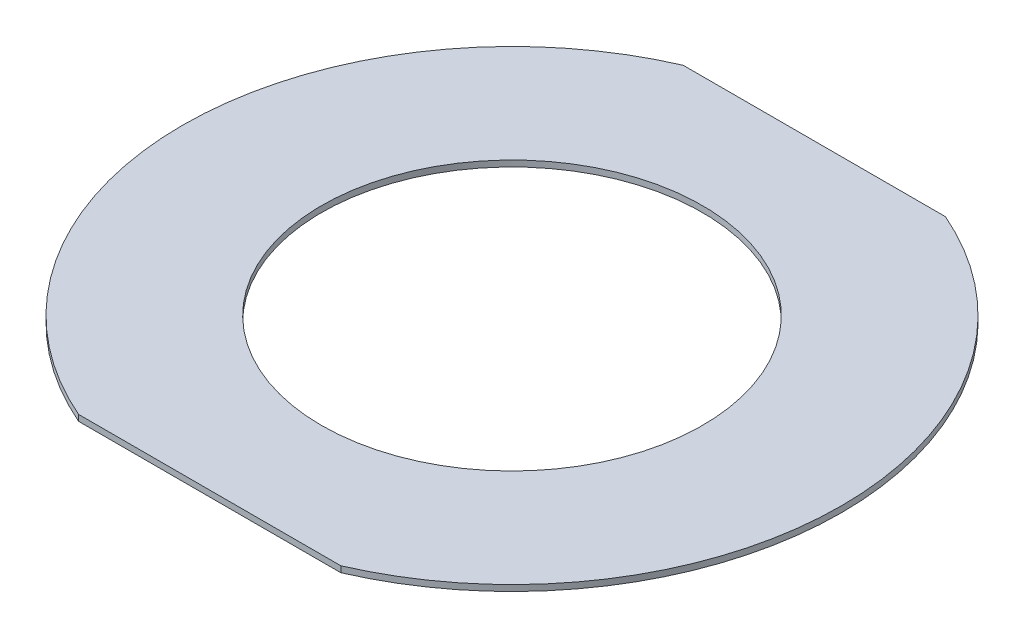
from build123d import *

# Parameters (mm, degrees)
SKETCH7_R           = 0.8001
BOSS_EXTRUDE3_DEPTH = 0.0254


with BuildPart() as part:
    # Sketch7 → Boss-Extrude3 (new body)
    with BuildSketch(Plane(origin=(0, 0, 0), x_dir=(1, 0, 0), z_dir=(0, 1, 0))):
        with BuildLine():
            Line((-0.55080531, 1.27), (0.55080531, 1.27))
            ThreePointArc((0.55080531, 1.27), (1.3843, 0), (0.55080531, -1.27))
            Line((0.55080531, -1.27), (-0.55080531, -1.27))
            ThreePointArc((-0.55080531, -1.27), (-1.3843, 0), (-0.55080531, 1.27))
        make_face()
        Circle(SKETCH7_R, mode=Mode.SUBTRACT)
    extrude(amount=BOSS_EXTRUDE3_DEPTH)


solid = part.part
